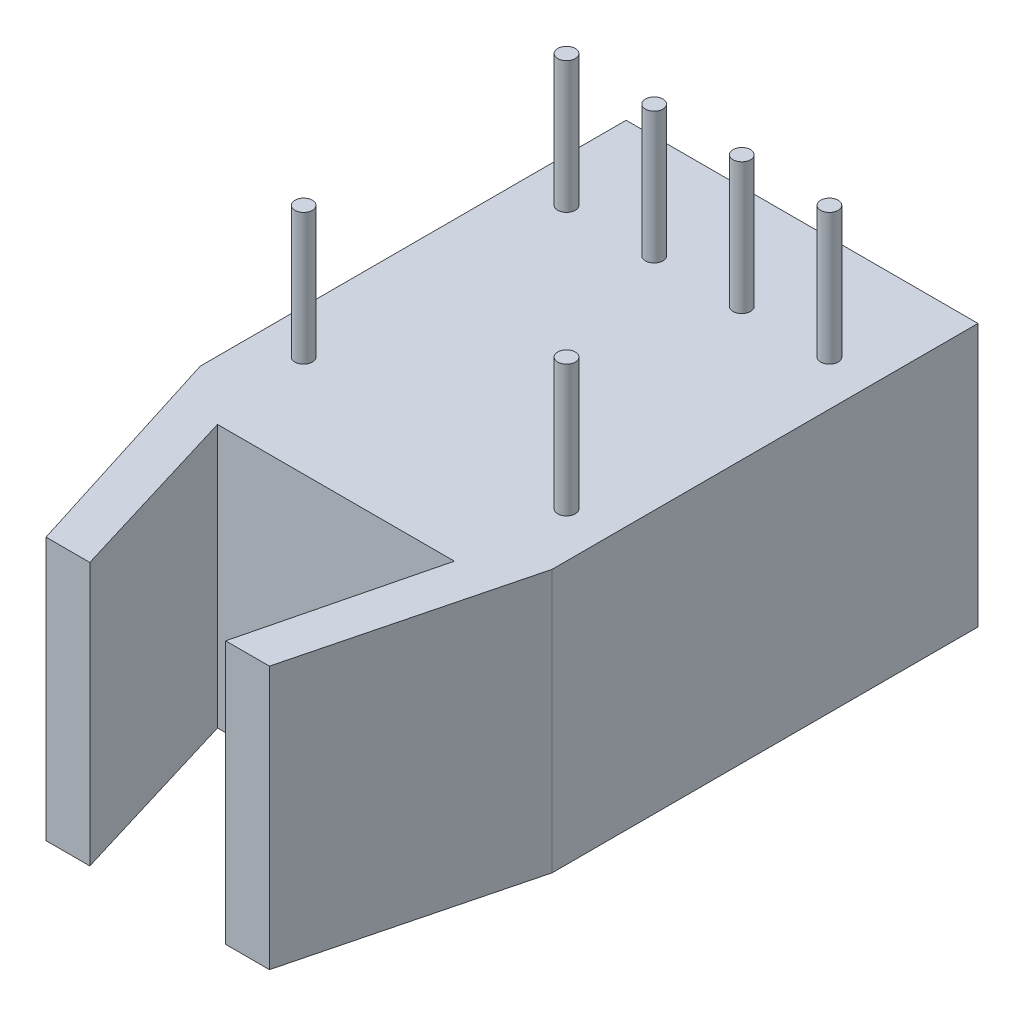
from build123d import *

# Parameters (mm, degrees)
HFBR_BASE_W          = 10.2
HFBR_BASE_H          = 12.3444
EXTRUDE1_DEPTH       = 7.62
EXTRUDE2_DEPTH       = 7.62
SKETCH3_R            = 0.254
PINS_DEPTH           = 3.81
LPATTERN1_COUNT      = 4
LPATTERN1_PITCH      = 2.54
LPATTERN1_COUNT_DIR2 = 2
LPATTERN1_PITCH_DIR2 = 7.62


with BuildPart() as part:
    # HFBR Base → Extrude1 (new body)
    with BuildSketch(Plane(origin=(0, 0, 0), x_dir=(1, 0, 0), z_dir=(0, 1, 0))):
        with Locations((5.1, -6.1722)):
            Rectangle(HFBR_BASE_W, HFBR_BASE_H)
    extrude(amount=EXTRUDE1_DEPTH)

    # Sketch2 → Extrude2 (add)
    with BuildSketch(Plane(origin=(0, 7.62, 0), x_dir=(-1, 0, 0), z_dir=(0, 1, 0))):
        Polygon((0, 12.3444), (-2.056727008, 18.8722), (-3.326727008, 18.8722), (-1.71375929, 13.55750012), (-8.579624915, 13.55750012), (-7.263727008, 18.8722), (-8.533727008, 18.8722), (-10.2, 12.3444), align=None)
    extrude(amount=-EXTRUDE2_DEPTH)

    # Sketch3 → Pins (add)
    with BuildSketch(Plane(origin=(0, 7.62, 0), x_dir=(-1, 0, 0), z_dir=(0, 1, 0))):
        with Locations((-1.27, 2.9972)):
            Circle(SKETCH3_R)
    pins = extrude(amount=PINS_DEPTH)

    # LPattern1: Pins 4 × 2, 2 skipped
    with Locations(*[(i * LPATTERN1_PITCH, 0, j * LPATTERN1_PITCH_DIR2) for i in range(LPATTERN1_COUNT) for j in range(LPATTERN1_COUNT_DIR2) if (i, j) not in ((0, 0), (1, 1), (2, 1))]):
        add(pins)


solid = part.part
